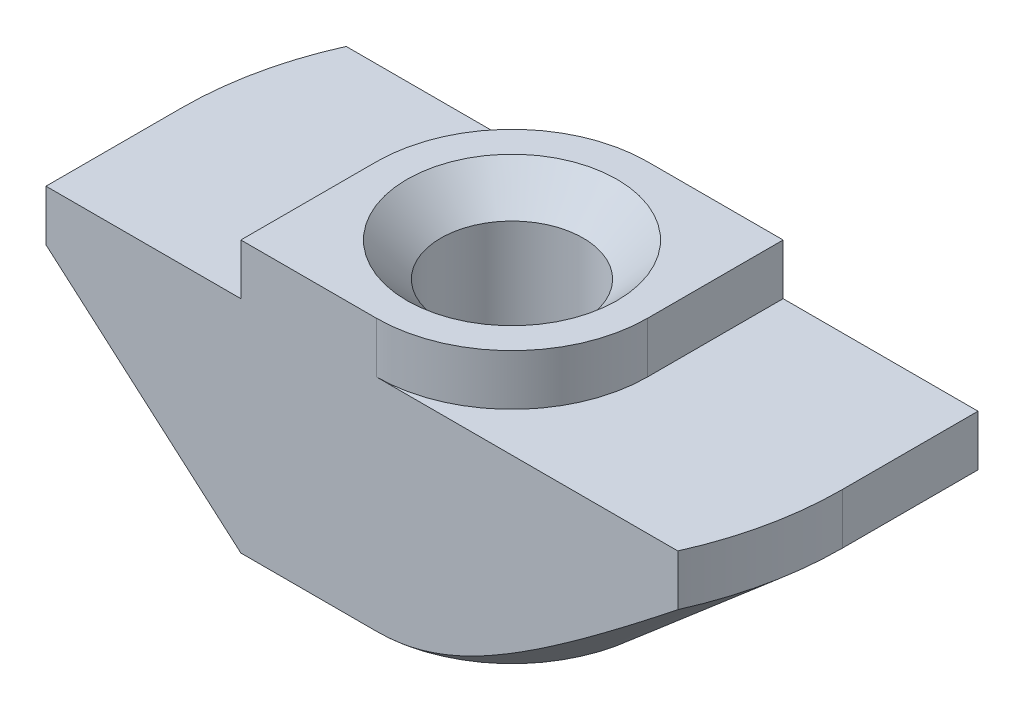
from build123d import *

# Parameters (mm, degrees)
EXTRUDE_1_DEPTH     = 4
CUT_EXTRUDE_1_DEPTH = 1.5
CUT_EXTRUDE_2_DEPTH = 7.5


with BuildPart() as part:
    # Эскиз1 → Бобышка-Вытянуть1 (new body, symmetric)
    with BuildSketch(Plane.XY):
        Polygon((4, 0), (-4, 0), (-4, -1.5), (-9.75, -1.5), (-9.75, -8), (9.75, -8), (9.75, -1.5), (4, -1.5), align=None)
    extrude(amount=EXTRUDE_1_DEPTH, both=True)

    # Эскиз3 → Отверстие обработанное метчиком M53 (revolve, cut)
    with BuildSketch(Plane(origin=(0, 0, 0), x_dir=(0, 0, 1), z_dir=(1, 0, 0))):
        Polygon((0, 0), (0, 8), (3.1, 8), (2.1, 7), (2.1, 1), (3.1, 0), align=None)
    revolve(axis=Axis((0, 6.35, 0), (0, -1, 0)), mode=Mode.SUBTRACT)

    # Эскиз4 → Вырез-Вытянуть1 (cut)
    with BuildSketch(Plane(origin=(0, 0, 0), x_dir=(1, 0, 0), z_dir=(0, 1, 0))):
        with BuildLine():
            Line((-4, 4), (-4, 0))
            ThreePointArc((-4, 0), (-2.828427125, 2.828427125), (0, 4))
            Line((0, 4), (-4, 4))
        make_face()
        with BuildLine():
            Line((0, -4), (4, -4))
            Line((4, -4), (4, 0))
            ThreePointArc((4, 0), (2.828427125, -2.828427125), (0, -4))
        make_face()
    extrude(amount=-CUT_EXTRUDE_1_DEPTH, mode=Mode.SUBTRACT)

    # Эскиз5 → Вырез-Вытянуть2 (cut, through all)
    with BuildSketch(Plane(origin=(0, -1.5, 0), x_dir=(1, 0, 0), z_dir=(0, 1, 0))):
        with BuildLine():
            Line((-9.75, 0), (-9.75, 4))
            Line((-9.75, 4), (-8.891709622, 4))
            ThreePointArc((-8.891709622, 4), (-9.533012871, 2.045523305), (-9.75, 0))
        make_face()
        with BuildLine():
            Line((9.75, 0), (9.75, -4))
            Line((9.75, -4), (8.891709622, -4))
            ThreePointArc((8.891709622, -4), (9.533012871, -2.045523305), (9.75, 0))
        make_face()
    extrude(amount=-CUT_EXTRUDE_2_DEPTH, mode=Mode.SUBTRACT)

    # Вырез-По траектории1: sweep along a path in Эскиз7
    with BuildLine(Plane.XZ.offset(8)) as sweep_1_path:
        Line((0, 9.75), (-9.75, 9.75))
        Line((-9.75, 9.75), (-9.75, 0))
        ThreePointArc((-9.75, 0), (-6.894291117, -6.894291117), (0, -9.75))
        Line((0, -9.75), (9.75, -9.75))
        Line((9.75, -9.75), (9.75, 0))
        ThreePointArc((9.75, 0), (6.894291117, 6.894291117), (0, 9.75))
    # Эскиз6 → Вырез-По траектории1 (sweep, cut)
    with BuildSketch(Plane.XY.offset(4)):
        Polygon((-9.75, -3), (-9.75, -8), (-4, -8), align=None)
    sweep(path=sweep_1_path.line, transition=Transition.RIGHT, mode=Mode.SUBTRACT)


solid = part.part
